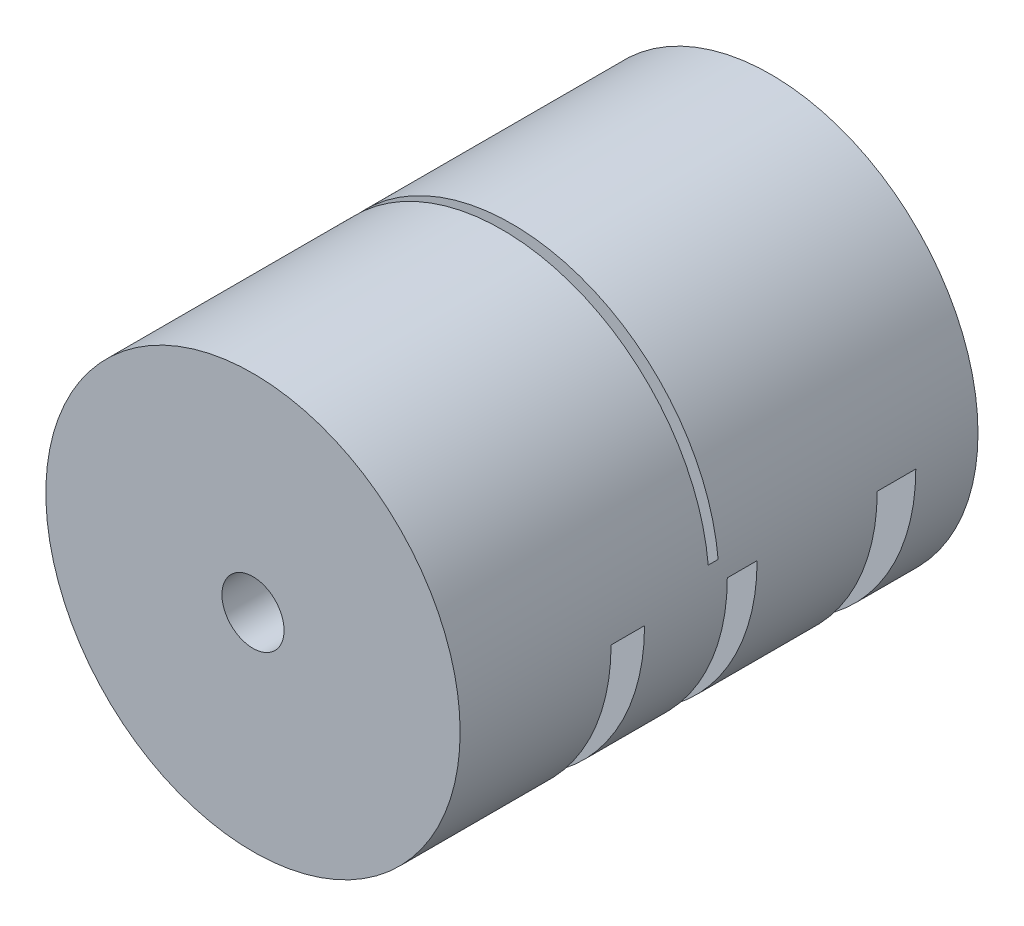
from build123d import *

# Parameters (mm, degrees)
SKETCH1_R           = 20
BOSS_EXTRUDE1_DEPTH = 25
CUT_EXTRUDE1_REACH  = 22
SKETCH2_W           = 45.354369025
SKETCH2_H           = 3.724754944
SKETCH2_H_2         = 2.877438925
SKETCH2_H_3         = 3.230053013
CUT_EXTRUDE2_REACH  = 22
SKETCH3_W           = 39.909801602
SKETCH3_H           = 0.954143847
SKETCH4_R           = 3
CUT_EXTRUDE3_DEPTH  = 51
SKETCH5_R           = 4
CUT_EXTRUDE4_DEPTH  = 10


with BuildPart() as part:
    # Sketch1 → Boss-Extrude1 (new body, symmetric)
    with BuildSketch(Plane.XY):
        Circle(SKETCH1_R)
    extrude(amount=BOSS_EXTRUDE1_DEPTH, both=True)

    # Sketch2 → Cut-Extrude1 (cut, up to next)
    with BuildSketch(Plane(origin=(0, 0, 0), x_dir=(1, 0, 0), z_dir=(0, 1, 0)), mode=Mode.PRIVATE) as cut_extrude1_sk1:
        with Locations((0.618163083, 17.131545904)):
            Rectangle(SKETCH2_W, SKETCH2_H)
    cut_extrude1_tool1 = extrude(cut_extrude1_sk1.sketch, amount=-CUT_EXTRUDE1_REACH, mode=Mode.PRIVATE) & part.part
    add(cut_extrude1_tool1.solids().sort_by_distance((0.618163, 0, -17.131546))[0], mode=Mode.SUBTRACT)
    # Sketch2 → Cut-Extrude1 (cut, up to next)
    with BuildSketch(Plane(origin=(0, 0, 0), x_dir=(1, 0, 0), z_dir=(0, 1, 0)), mode=Mode.PRIVATE) as cut_extrude1_sk2:
        with Locations((0.618163083, 2.232701411)):
            Rectangle(SKETCH2_W, SKETCH2_H_2)
    cut_extrude1_tool2 = extrude(cut_extrude1_sk2.sketch, amount=-CUT_EXTRUDE1_REACH, mode=Mode.PRIVATE) & part.part
    add(cut_extrude1_tool2.solids().sort_by_distance((0.618163, 0, -2.232701))[0], mode=Mode.SUBTRACT)
    # Sketch2 → Cut-Extrude1 (cut, up to next)
    with BuildSketch(Plane(origin=(0, 0, 0), x_dir=(1, 0, 0), z_dir=(0, 1, 0)), mode=Mode.PRIVATE) as cut_extrude1_sk3:
        with Locations((0.618163083, -8.81108963)):
            Rectangle(SKETCH2_W, SKETCH2_H_3)
    cut_extrude1_tool3 = extrude(cut_extrude1_sk3.sketch, amount=-CUT_EXTRUDE1_REACH, mode=Mode.PRIVATE) & part.part
    add(cut_extrude1_tool3.solids().sort_by_distance((0.618163, 0, 8.81109))[0], mode=Mode.SUBTRACT)

    # Sketch3 → Cut-Extrude2 (cut, up to next)
    with BuildSketch(Plane(origin=(0, 0, 0), x_dir=(1, 0, 0), z_dir=(0, 1, 0)), mode=Mode.PRIVATE) as cut_extrude2_sk1:
        with Locations((-0.045099199, -0.477071924)):
            Rectangle(SKETCH3_W, SKETCH3_H)
    cut_extrude2_tool1 = extrude(cut_extrude2_sk1.sketch, amount=CUT_EXTRUDE2_REACH, mode=Mode.PRIVATE) & part.part
    add(cut_extrude2_tool1.solids().sort_by_distance((-0.045099, 0, 0.477072))[0], mode=Mode.SUBTRACT)

    # Sketch4 → Cut-Extrude3 (cut, through all)
    with BuildSketch(Plane(origin=(0, 0, -25), x_dir=(-1, 0, 0), z_dir=(0, 0, -1))):
        Circle(SKETCH4_R)
    extrude(amount=-CUT_EXTRUDE3_DEPTH, mode=Mode.SUBTRACT)

    # Sketch5 → Cut-Extrude4 (cut)
    with BuildSketch(Plane(origin=(0, 0, -25), x_dir=(-1, 0, 0), z_dir=(0, 0, -1))):
        Circle(SKETCH5_R)
    extrude(amount=-CUT_EXTRUDE4_DEPTH, mode=Mode.SUBTRACT)


solid = part.part
